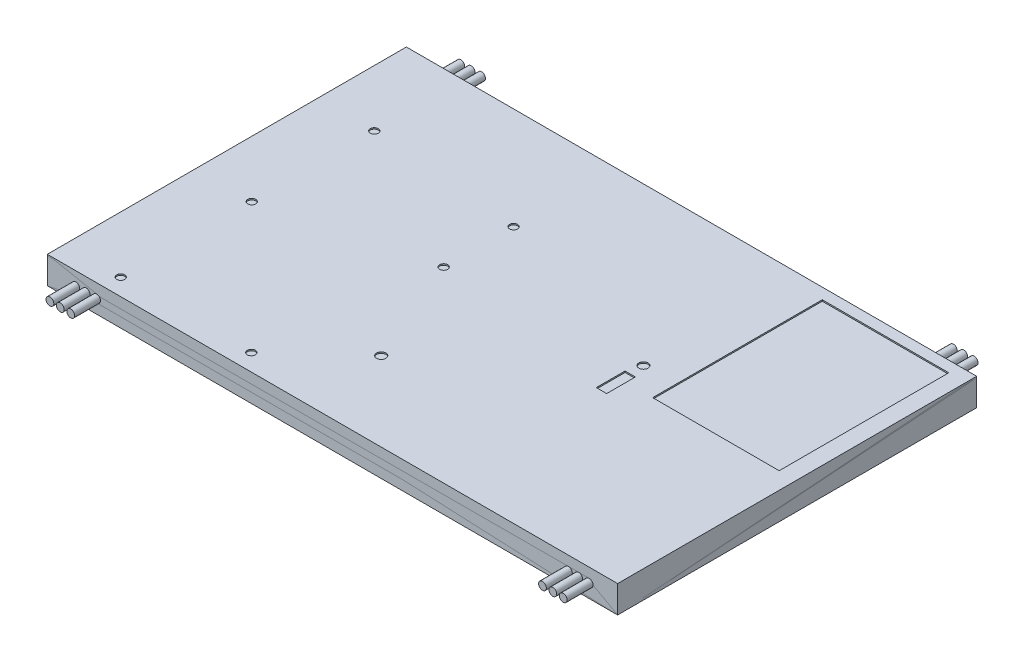
from build123d import *

# Parameters (mm, degrees)
SKETCH1_W               = 220
SKETCH1_H               = 138.5
BOSS_EXTRUDE1_DEPTH     = 10
BOSS_EXTRUDE3_DEPTH     = 10.51
SKETCH6_R               = 1.505
BOSS_EXTRUDE4_DEPTH     = 16.5
SKETCH7_W               = 48.809005083
SKETCH7_H               = 65.424836601
CUT_EXTRUDE1_DEPTH      = 75
CUT_EXTRUDE1_DEPTH_BACK = 81
SKETCH8_R               = 1.505
SKETCH8_R_2             = 1.55
BOSS_EXTRUDE5_DEPTH     = 12
SKETCH9_R               = 1.55
SKETCH9_R_2             = 1.775907256
SKETCH9_R_3             = 1.799574189
CUT_EXTRUDE2_DEPTH      = 65
CUT_EXTRUDE2_DEPTH_BACK = 51


with BuildPart() as part:
    # Sketch1 → Boss-Extrude1 (new body)
    with BuildSketch(Plane(origin=(0, 0, 0), x_dir=(1, 0, 0), z_dir=(0, 1, 0))):
        with Locations((3.035702614, 8.416584967)):
            Rectangle(SKETCH1_W, SKETCH1_H)
    extrude(amount=BOSS_EXTRUDE1_DEPTH)


with BuildPart() as body_2:
    # Sketch5 → Boss-Extrude3 (new body)
    with BuildSketch(Plane(origin=(0, 0, 0), x_dir=(1, 0, 0), z_dir=(0, 1, 0))):
        Polygon((-106.964297386, 8.416584967), (-106.964297386, 77.666584967), (113.035702614, 77.666584967), (113.035702614, -60.833415033), (-106.964297386, -60.833415033), align=None)
    extrude(amount=BOSS_EXTRUDE3_DEPTH)

    # Sketch6 → Boss-Extrude4 (add)
    with BuildSketch(Plane.XY.offset(70.833415033)):
        with Locations((-95.964297386, 5.255)):
            Circle(SKETCH6_R)
        with Locations((-91.954297386, 5.255)):
            Circle(SKETCH6_R)
        with Locations((-87.944297386, 5.255)):
            Circle(SKETCH6_R)
        with Locations((94.045702614, 5.255)):
            Circle(SKETCH6_R)
        with Locations((98.045702614, 5.255)):
            Circle(SKETCH6_R)
        with Locations((102.045702614, 5.255)):
            Circle(SKETCH6_R)
    extrude(amount=-BOSS_EXTRUDE4_DEPTH)

    # Sketch7 → Cut-Extrude1 (cut, two sides)
    with BuildSketch(Plane(origin=(0, 0, 0), x_dir=(1, 0, 0), z_dir=(0, 1, 0))) as cut_extrude1_sk:
        with Locations((82.090713507, 40.739569717)):
            Rectangle(SKETCH7_W, SKETCH7_H)
    extrude(amount=CUT_EXTRUDE1_DEPTH, mode=Mode.SUBTRACT)
    extrude(cut_extrude1_sk.sketch, amount=-CUT_EXTRUDE1_DEPTH_BACK, mode=Mode.SUBTRACT)

    # Sketch8 → Boss-Extrude5 (add)
    with BuildSketch(Plane(origin=(0, 0, -87.666584967), x_dir=(-1, 0, 0), z_dir=(0, 0, -1))):
        with Locations((-102.045702614, 5.255)):
            Circle(SKETCH8_R)
        with Locations((-98.045702614, 5.255)):
            Circle(SKETCH8_R_2)
        with Locations((-94.045702614, 5.255)):
            Circle(SKETCH8_R)
        with Locations((95.964297386, 5.255)):
            Circle(SKETCH8_R)
        with Locations((91.954297386, 5.255)):
            Circle(SKETCH8_R)
        with Locations((87.944297386, 5.255)):
            Circle(SKETCH8_R)
    extrude(amount=-BOSS_EXTRUDE5_DEPTH)

    # Sketch9 → Cut-Extrude2 (cut, two sides)
    with BuildSketch(Plane(origin=(0, 0, 0), x_dir=(1, 0, 0), z_dir=(0, 1, 0))) as cut_extrude2_sk:
        with Locations((-85.161319051, -54.29455425)):
            Circle(SKETCH9_R)
        with Locations((-34.781319051, -54.29455425)):
            Circle(SKETCH9_R)
        with Locations((-85.10609114, -3.825384854)):
            Circle(SKETCH9_R)
        with Locations((-26.25609114, 11.374615146)):
            Circle(SKETCH9_R)
        with Locations((-26.25609114, 38.334615146)):
            Circle(SKETCH9_R)
        with Locations((-85.10609114, 43.434615146)):
            Circle(SKETCH9_R)
        with Locations((45.180112097, 16.995575273)):
            Circle(SKETCH9_R_2)
        with Locations((-8.688678328, -30.298677737)):
            Circle(SKETCH9_R_3)
        Polygon((43.455602968, 0.519563371), (47.452049454, 0.519563371), (47.455602968, 11.605206961), (43.455602968, 11.605206961), align=None)
    extrude(amount=CUT_EXTRUDE2_DEPTH, mode=Mode.SUBTRACT)
    extrude(cut_extrude2_sk.sketch, amount=-CUT_EXTRUDE2_DEPTH_BACK, mode=Mode.SUBTRACT)


solid = Compound([part.part, body_2.part])
